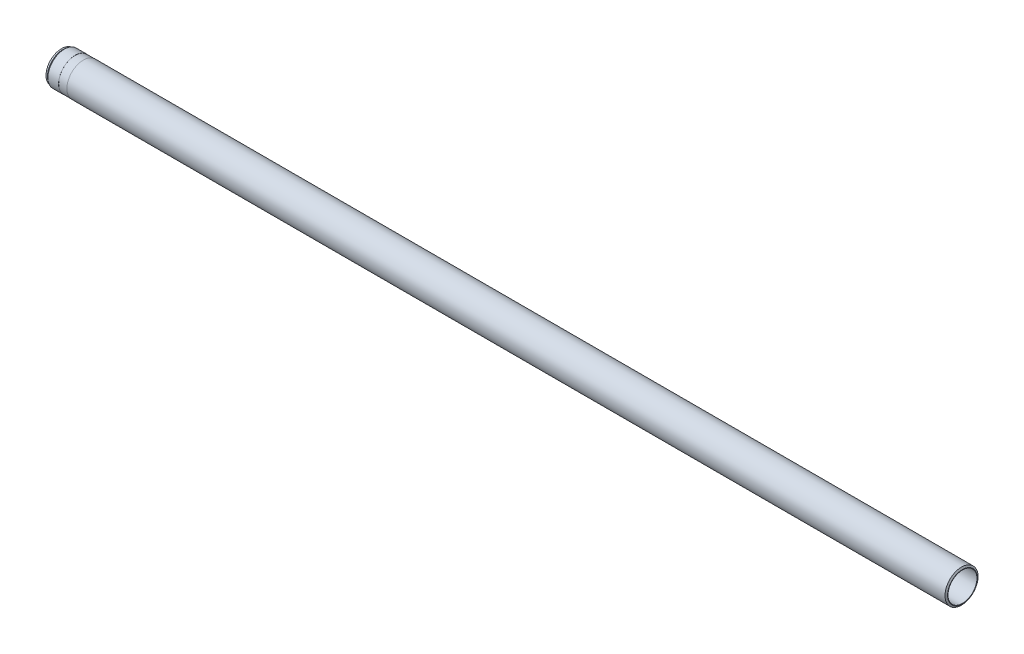
from build123d import *


with BuildPart() as part:
    # Sketch1 → Base-Revolve (revolve)
    with BuildSketch(Plane.XY):
        Polygon((0, 35), (0, 36), (-2.309401077, 40), (-2128, 40), (-2128, 39.75), (-2148, 39.75), (-2148, 40), (-2173.929629983, 40), (-2177.5, 37.5), (-2181, 37.5), (-2181, 35.727350269), (-2180, 35.15), (-2166, 35.15), (-2165.740192379, 35), align=None)
    revolve(axis=Axis((-122.784188742, 0, 0), (1, 0, 0)))


solid = part.part
